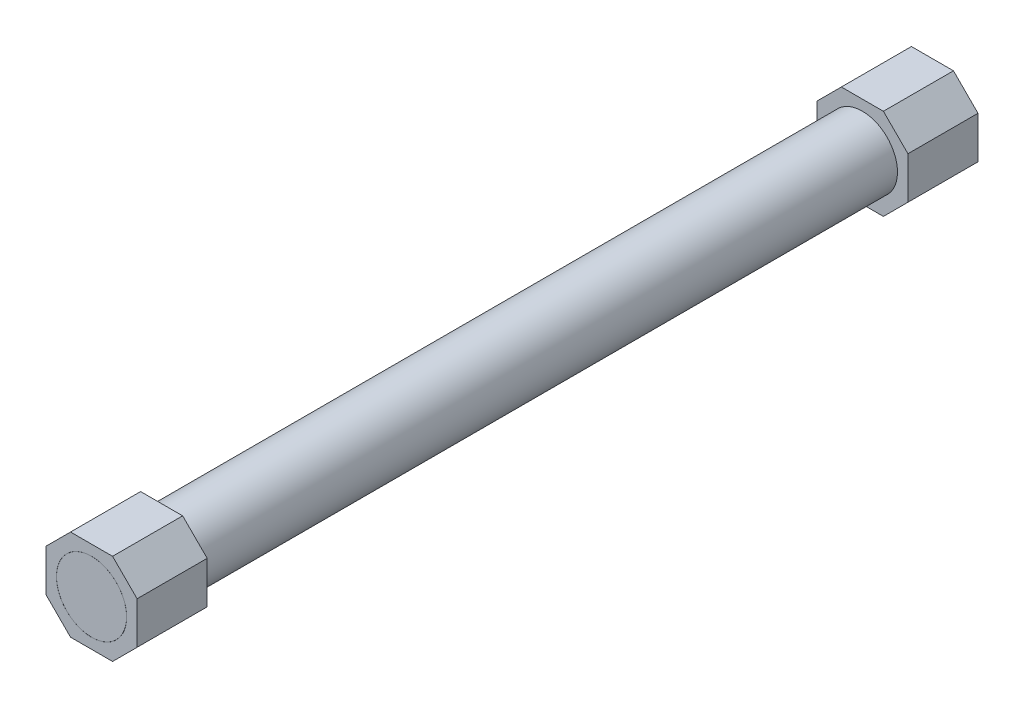
from build123d import *

# Parameters (mm, degrees)
SKETCH1_R           = 5
BOSS_EXTRUDE1_DEPTH = 120
SKETCH2_R           = 5.01
BOSS_EXTRUDE2_DEPTH = 10


with BuildPart() as part:
    # Sketch1 → Boss-Extrude1 (new body)
    with BuildSketch(Plane.XY):
        Circle(SKETCH1_R)
    extrude(amount=BOSS_EXTRUDE1_DEPTH)


with BuildPart() as body_2:
    # Sketch2 → Boss-Extrude2 (new body)
    with BuildSketch(Plane.XY.offset(120)):
        Polygon((3, 6.5), (-3, 6.5), (-6.5, 3), (-6.5, -3), (-3, -6.5), (3, -6.5), (6.5, -3), (6.5, 3), align=None)
        Circle(SKETCH2_R, mode=Mode.SUBTRACT)
    extrude(amount=-BOSS_EXTRUDE2_DEPTH)


with BuildPart() as body_3:
    # Mirror1: mirrored copy
    add(body_2.part.mirror(Plane(origin=(0, 0, 60), x_dir=(1, 0, 0), z_dir=(0, 0, -1))))


solid = Compound([part.part, body_2.part, body_3.part])
